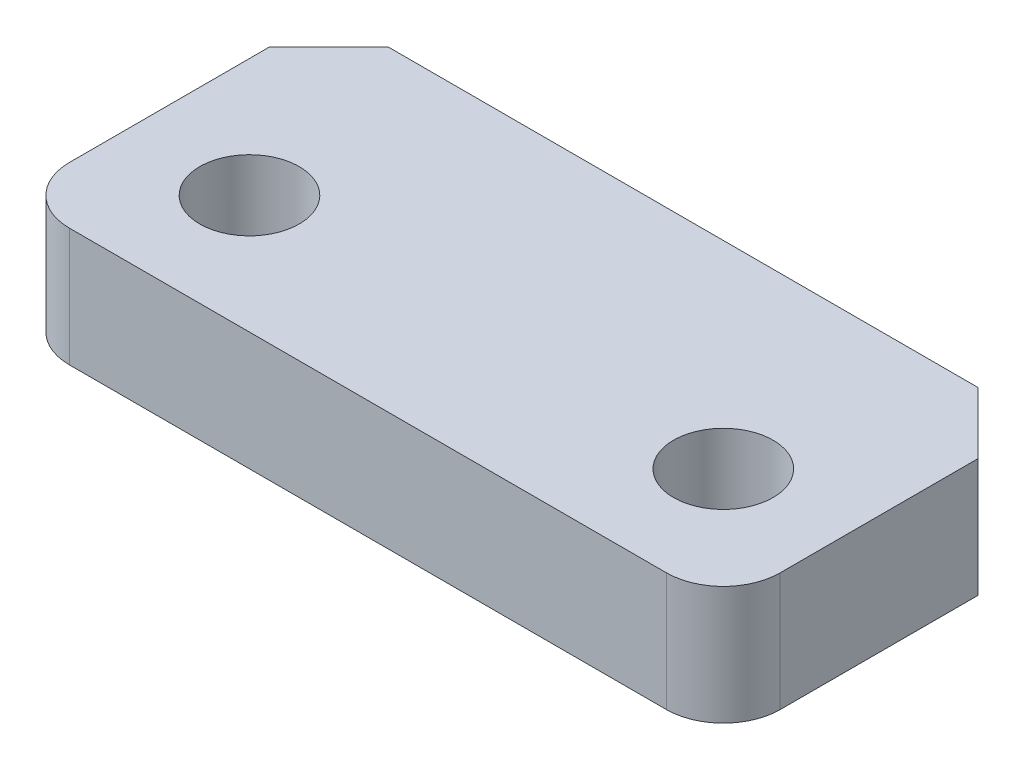
from build123d import *

# Parameters (mm, degrees)
SKETCH1_W           = 38.1
SKETCH1_H           = 21.209
BOSS_EXTRUDE1_DEPTH = 6.35
SKETCH2_R           = 2.667
CUT_EXTRUDE1_DEPTH  = 9.525
CUT_EXTRUDE2_DEPTH  = 9.525
CUT_EXTRUDE4_DEPTH  = 9.525
FILLET2_R           = 3.048


with BuildPart() as part:
    # Sketch1 → Boss-Extrude1 (new body)
    with BuildSketch(Plane(origin=(0, 0, 0), x_dir=(1, 0, 0), z_dir=(0, 1, 0))):
        Rectangle(SKETCH1_W, SKETCH1_H)
    extrude(amount=BOSS_EXTRUDE1_DEPTH)

    # Sketch2 → Cut-Extrude1 (cut)
    with BuildSketch(Plane(origin=(0, 6.35, 0), x_dir=(1, 0, 0), z_dir=(0, 1, 0))):
        with Locations((-12.7, 0)):
            Circle(SKETCH2_R)
        with Locations((12.7, 0)):
            Circle(SKETCH2_R)
    extrude(amount=-CUT_EXTRUDE1_DEPTH, mode=Mode.SUBTRACT)

    # Sketch3 → Cut-Extrude2 (cut)
    with BuildSketch(Plane(origin=(0, 6.35, 0), x_dir=(1, 0, 0), z_dir=(0, 1, 0))):
        Polygon((-19.05, 10.6045), (-15.875, 10.6045), (-19.05, 7.4295), align=None)
        Polygon((19.05, 10.6045), (15.748, 10.6045), (19.05, 7.3025), align=None)
        Polygon((19.05, -10.6045), (15.748, -10.6045), (19.05, -7.3025), align=None)
        Polygon((-19.05, -10.6045), (-15.875, -10.6045), (-19.05, -7.4295), align=None)
    extrude(amount=-CUT_EXTRUDE2_DEPTH, mode=Mode.SUBTRACT)

    # Sketch4 → Cut-Extrude4 (cut)
    with BuildSketch(Plane(origin=(0, 6.35, 0), x_dir=(1, 0, 0), z_dir=(0, 1, 0))):
        Polygon((-19.05, -7.4295), (-15.875, -10.6045), (-15.875, -6.35), (-19.05, -6.35), align=None)
        Polygon((15.748, -10.6045), (19.05, -7.3025), (19.05, -6.35), (-15.875, -6.35), (-15.875, -10.6045), align=None)
    extrude(amount=-CUT_EXTRUDE4_DEPTH, mode=Mode.SUBTRACT)

    # Fillet2
    fillet2_edges = [part.edges().sort_by_distance(p)[0] for p in [
        (-19.05, 3.175, 6.35),
        (19.05, 3.175, 6.35),
    ]]
    fillet(fillet2_edges, radius=FILLET2_R)


solid = part.part
